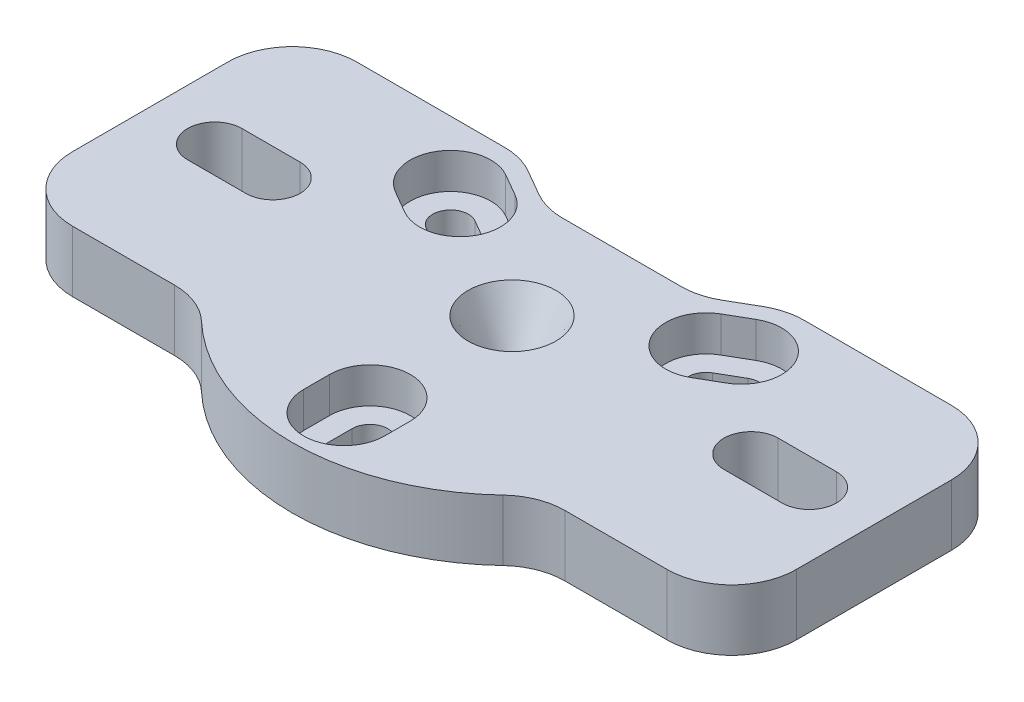
from build123d import *

# Parameters (mm, degrees)
SKETCH1_R           = 1.778
BOSS_EXTRUDE1_DEPTH = 6
CUT_EXTRUDE1_DEPTH  = 3.5
CHAMFER1_SIZE       = 2.54
CHAMFER1_SIZE2      = 5.08


with BuildPart() as part:
    # Sketch1 → Boss-Extrude1 (new body)
    with BuildSketch(Plane(origin=(0, 0, 0), x_dir=(1, 0, 0), z_dir=(0, 1, 0))):
        with BuildLine():
            Line((14.722227154, 13.97), (29.21, 13.97))
            ThreePointArc((29.21, 13.97), (33.700128061, 12.110128061), (35.56, 7.62))
            Line((35.56, 7.62), (35.56, -7.62))
            ThreePointArc((35.56, -7.62), (33.700128061, -12.110128061), (29.21, -13.97))
            Line((29.21, -13.97), (19.176579466, -13.97))
            ThreePointArc((19.176579466, -13.97), (16.831686562, -14.418815604), (14.818265951, -15.701818182))
            ThreePointArc((14.818265951, -15.701818182), (0, -21.59), (-14.818265951, -15.701818182))
            ThreePointArc((-14.818265951, -15.701818182), (-16.831686562, -14.418815604), (-19.176579466, -13.97))
            Line((-19.176579466, -13.97), (-29.21, -13.97))
            ThreePointArc((-29.21, -13.97), (-33.700128061, -12.110128061), (-35.56, -7.62))
            Line((-35.56, -7.62), (-35.56, 7.62))
            ThreePointArc((-35.56, 7.62), (-33.700128061, 12.110128061), (-29.21, 13.97))
            Line((-29.21, 13.97), (-14.722227154, 13.97))
            ThreePointArc((-14.722227154, 13.97), (-13.078726217, 13.753628997), (-11.547227154, 13.119261314))
            Line((-11.547227154, 13.119261314), (-8.995011096, 11.645738686))
            ThreePointArc((-8.995011096, 11.645738686), (-7.463512032, 11.011371003), (-5.820011096, 10.795))
            Line((-5.820011096, 10.795), (5.820011096, 10.795))
            ThreePointArc((5.820011096, 10.795), (7.463512032, 11.011371003), (8.995011096, 11.645738686))
            Line((8.995011096, 11.645738686), (11.547227154, 13.119261314))
            ThreePointArc((11.547227154, 13.119261314), (13.078726217, 13.753628997), (14.722227154, 13.97))
        make_face()
        Circle(SKETCH1_R, mode=Mode.SUBTRACT)
        with BuildLine():
            Line((-23.495, -2.667), (-29.21, -2.667))
            ThreePointArc((-29.21, -2.667), (-31.877, 0), (-29.21, 2.667))
            Line((-29.21, 2.667), (-23.495, 2.667))
            ThreePointArc((-23.495, 2.667), (-20.828, 0), (-23.495, -2.667))
        make_face(mode=Mode.SUBTRACT)
        with BuildLine():
            Line((23.495, 2.667), (29.21, 2.667))
            ThreePointArc((29.21, 2.667), (31.877, 0), (29.21, -2.667))
            Line((29.21, -2.667), (23.495, -2.667))
            ThreePointArc((23.495, -2.667), (20.828, 0), (23.495, 2.667))
        make_face(mode=Mode.SUBTRACT)
        with BuildLine():
            Line((-15.164419162, 6.734455543), (-12.964714637, 5.464455543))
            ThreePointArc((-12.964714637, 5.464455543), (-10.57417018, 6.105), (-11.214714637, 8.495544457))
            Line((-11.214714637, 8.495544457), (-13.414419162, 9.765544457))
            ThreePointArc((-13.414419162, 9.765544457), (-15.804963619, 9.125), (-15.164419162, 6.734455543))
        make_face(mode=Mode.SUBTRACT)
        with BuildLine():
            Line((13.414419162, 9.765544457), (11.214714637, 8.495544457))
            ThreePointArc((11.214714637, 8.495544457), (10.57417018, 6.105), (12.964714637, 5.464455543))
            Line((12.964714637, 5.464455543), (15.164419162, 6.734455543))
            ThreePointArc((15.164419162, 6.734455543), (15.804963619, 9.125), (13.414419162, 9.765544457))
        make_face(mode=Mode.SUBTRACT)
        with BuildLine():
            Line((1.75, -16.5), (1.75, -13.96))
            ThreePointArc((1.75, -13.96), (0, -12.21), (-1.75, -13.96))
            Line((-1.75, -13.96), (-1.75, -16.5))
            ThreePointArc((-1.75, -16.5), (0, -18.25), (1.75, -16.5))
        make_face(mode=Mode.SUBTRACT)
    extrude(amount=BOSS_EXTRUDE1_DEPTH)

    # Sketch5 → Cut-Extrude1 (cut)
    with BuildSketch(Plane(origin=(0, 6, 0), x_dir=(1, 0, 0), z_dir=(0, 1, 0))):
        with BuildLine():
            Line((-3.96875, -13.96), (-3.96875, -16.5))
            ThreePointArc((-3.96875, -16.5), (0, -20.46875), (3.96875, -16.5))
            Line((3.96875, -16.5), (3.96875, -13.96))
            ThreePointArc((3.96875, -13.96), (0, -9.99125), (-3.96875, -13.96))
        make_face()
        with BuildLine():
            Line((12.305044162, 11.687038321), (10.105339637, 10.417038321))
            ThreePointArc((10.105339637, 10.417038321), (8.652676316, 4.995625), (14.074089637, 3.542961679))
            Line((14.074089637, 3.542961679), (16.273794162, 4.812961679))
            ThreePointArc((16.273794162, 4.812961679), (17.726457484, 10.234375), (12.305044162, 11.687038321))
        make_face()
        with BuildLine():
            Line((-12.305044162, 11.687038321), (-10.105339637, 10.417038321))
            ThreePointArc((-10.105339637, 10.417038321), (-8.652676316, 4.995625), (-14.074089637, 3.542961679))
            Line((-14.074089637, 3.542961679), (-16.273794162, 4.812961679))
            ThreePointArc((-16.273794162, 4.812961679), (-17.726457484, 10.234375), (-12.305044162, 11.687038321))
        make_face()
    extrude(amount=-CUT_EXTRUDE1_DEPTH, mode=Mode.SUBTRACT)

    # Chamfer1
    chamfer1_edges = [part.edges().sort_by_distance(p)[0] for p in [
        (-1.778, 6, 0),
    ]]
    chamfer1_side = [part.faces().sort_by_distance(p)[0] for p in [
        (0, 6, 2.195443335),
    ]]
    chamfer(chamfer1_edges, length=CHAMFER1_SIZE, length2=CHAMFER1_SIZE2, reference=chamfer1_side[0])


solid = part.part
